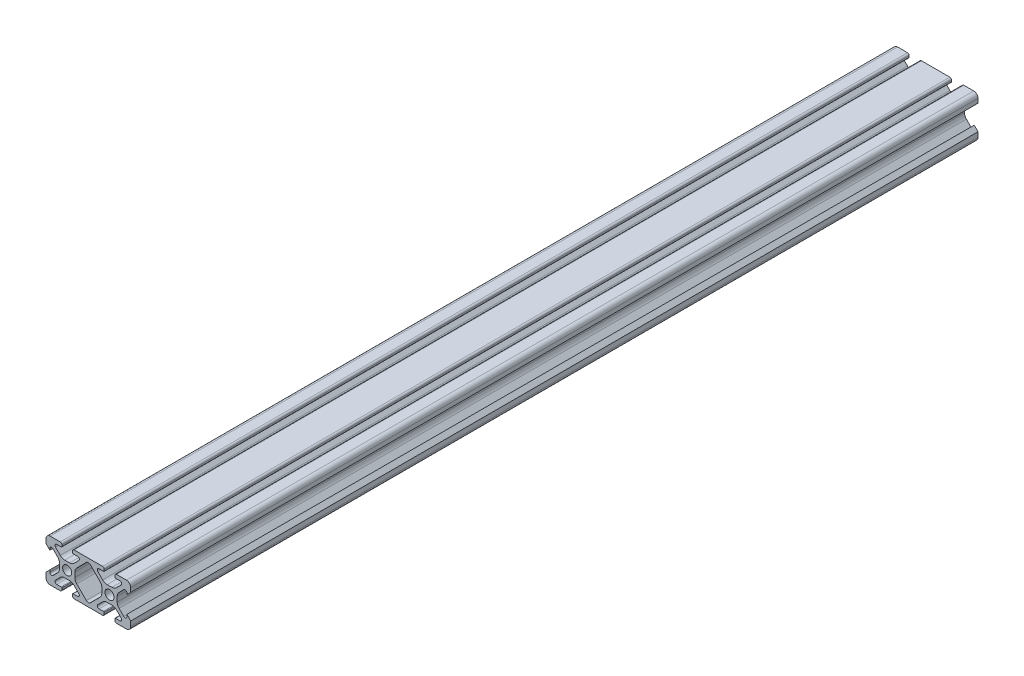
from build123d import *

# Parameters (mm, degrees)
SKETCH1_R           = 2.1463
BOSS_EXTRUDE1_DEPTH = 400
CUT_EXTRUDE1_DEPTH  = 401


with BuildPart() as part:
    # Sketch1 → Boss-Extrude1 (new body)
    with BuildSketch(Plane.XY):
        with BuildLine():
            Line((-19.9898, 7.9883), (-19.9898, 3.2893))
            ThreePointArc((-19.9898, 3.2893), (-19.75917588, 2.73252412), (-19.2024, 2.5019))
            Line((-19.2024, 2.5019), (-18.4912, 2.5019))
            ThreePointArc((-18.4912, 2.5019), (-18.275673853, 2.591173853), (-18.1864, 2.8067))
            Line((-18.1864, 2.8067), (-18.1864, 4.9149))
            ThreePointArc((-18.1864, 4.9149), (-17.668965253, 5.689295824), (-16.755503096, 5.507596904))
            Line((-16.755503096, 5.507596904), (-14.500665747, 3.252759555))
            ThreePointArc((-14.500665747, 3.252759555), (-13.850954457, 2.280397894), (-13.622806192, 1.133419111))
            Line((-13.622806192, 1.133419111), (-13.622806192, -1.133419111))
            ThreePointArc((-13.622806192, -1.133419111), (-13.850954457, -2.280397894), (-14.500665747, -3.252759555))
            Line((-14.500665747, -3.252759555), (-16.755503096, -5.507596904))
            ThreePointArc((-16.755503096, -5.507596904), (-17.668965253, -5.689295824), (-18.1864, -4.9149))
            Line((-18.1864, -4.9149), (-18.1864, -2.8067))
            ThreePointArc((-18.1864, -2.8067), (-18.275673853, -2.591173853), (-18.4912, -2.5019))
            Line((-18.4912, -2.5019), (-19.2024, -2.5019))
            ThreePointArc((-19.2024, -2.5019), (-19.75917588, -2.73252412), (-19.9898, -3.2893))
            Line((-19.9898, -3.2893), (-19.9898, -7.9883))
            ThreePointArc((-19.9898, -7.9883), (-19.402080467, -9.407180467), (-17.9832, -9.9949))
            Line((-17.9832, -9.9949), (-13.2842, -9.9949))
            ThreePointArc((-13.2842, -9.9949), (-12.72742412, -9.76427588), (-12.4968, -9.2075))
            Line((-12.4968, -9.2075), (-12.4968, -8.4963))
            ThreePointArc((-12.4968, -8.4963), (-12.586073853, -8.280773853), (-12.8016, -8.1915))
            Line((-12.8016, -8.1915), (-14.9098, -8.1915))
            ThreePointArc((-14.9098, -8.1915), (-15.684195824, -7.674065253), (-15.502496904, -6.760603096))
            Line((-15.502496904, -6.760603096), (-13.247659555, -4.505765747))
            ThreePointArc((-13.247659555, -4.505765747), (-12.275297894, -3.856054457), (-11.128319111, -3.627906192))
            Line((-11.128319111, -3.627906192), (-8.861480889, -3.627906192))
            ThreePointArc((-8.861480889, -3.627906192), (-7.714502106, -3.856054457), (-6.742140445, -4.505765747))
            Line((-6.742140445, -4.505765747), (-4.487303096, -6.760603096))
            ThreePointArc((-4.487303096, -6.760603096), (-4.305604176, -7.674065253), (-5.08, -8.1915))
            Line((-5.08, -8.1915), (-7.1882, -8.1915))
            ThreePointArc((-7.1882, -8.1915), (-7.403726147, -8.280773853), (-7.493, -8.4963))
            Line((-7.493, -8.4963), (-7.493, -9.2075))
            ThreePointArc((-7.493, -9.2075), (-7.26237588, -9.76427588), (-6.7056, -9.9949))
            Line((-6.7056, -9.9949), (0, -9.9949))
            Line((0, -9.9949), (6.7056, -9.9949))
            ThreePointArc((6.7056, -9.9949), (7.26237588, -9.76427588), (7.493, -9.2075))
            Line((7.493, -9.2075), (7.493, -8.4963))
            ThreePointArc((7.493, -8.4963), (7.403726147, -8.280773853), (7.1882, -8.1915))
            Line((7.1882, -8.1915), (5.08, -8.1915))
            ThreePointArc((5.08, -8.1915), (4.305604176, -7.674065253), (4.487303096, -6.760603096))
            Line((4.487303096, -6.760603096), (6.742140445, -4.505765747))
            ThreePointArc((6.742140445, -4.505765747), (7.714502106, -3.856054457), (8.861480889, -3.627906192))
            Line((8.861480889, -3.627906192), (11.128319111, -3.627906192))
            ThreePointArc((11.128319111, -3.627906192), (12.275297894, -3.856054457), (13.247659555, -4.505765747))
            Line((13.247659555, -4.505765747), (15.502496904, -6.760603096))
            ThreePointArc((15.502496904, -6.760603096), (15.684195824, -7.674065253), (14.9098, -8.1915))
            Line((14.9098, -8.1915), (12.8016, -8.1915))
            ThreePointArc((12.8016, -8.1915), (12.586073853, -8.280773853), (12.4968, -8.4963))
            Line((12.4968, -8.4963), (12.4968, -9.2075))
            ThreePointArc((12.4968, -9.2075), (12.72742412, -9.76427588), (13.2842, -9.9949))
            Line((13.2842, -9.9949), (17.9832, -9.9949))
            ThreePointArc((17.9832, -9.9949), (19.402080467, -9.407180467), (19.9898, -7.9883))
            Line((19.9898, -7.9883), (19.9898, -3.2893))
            ThreePointArc((19.9898, -3.2893), (19.75917588, -2.73252412), (19.2024, -2.5019))
            Line((19.2024, -2.5019), (18.4912, -2.5019))
            ThreePointArc((18.4912, -2.5019), (18.275673853, -2.591173853), (18.1864, -2.8067))
            Line((18.1864, -2.8067), (18.1864, -4.9149))
            ThreePointArc((18.1864, -4.9149), (17.668965253, -5.689295824), (16.755503096, -5.507596904))
            Line((16.755503096, -5.507596904), (14.500665747, -3.252759555))
            ThreePointArc((14.500665747, -3.252759555), (13.850954457, -2.280397894), (13.622806192, -1.133419111))
            Line((13.622806192, -1.133419111), (13.622806192, 1.133419111))
            ThreePointArc((13.622806192, 1.133419111), (13.850954457, 2.280397894), (14.500665747, 3.252759555))
            Line((14.500665747, 3.252759555), (16.755503096, 5.507596904))
            ThreePointArc((16.755503096, 5.507596904), (17.668965253, 5.689295824), (18.1864, 4.9149))
            Line((18.1864, 4.9149), (18.1864, 2.8067))
            ThreePointArc((18.1864, 2.8067), (18.275673853, 2.591173853), (18.4912, 2.5019))
            Line((18.4912, 2.5019), (19.2024, 2.5019))
            ThreePointArc((19.2024, 2.5019), (19.75917588, 2.73252412), (19.9898, 3.2893))
            Line((19.9898, 3.2893), (19.9898, 7.9883))
            ThreePointArc((19.9898, 7.9883), (19.402080467, 9.407180467), (17.9832, 9.9949))
            Line((17.9832, 9.9949), (13.2842, 9.9949))
            ThreePointArc((13.2842, 9.9949), (12.72742412, 9.76427588), (12.4968, 9.2075))
            Line((12.4968, 9.2075), (12.4968, 8.4963))
            ThreePointArc((12.4968, 8.4963), (12.586073853, 8.280773853), (12.8016, 8.1915))
            Line((12.8016, 8.1915), (14.9098, 8.1915))
            ThreePointArc((14.9098, 8.1915), (15.684195824, 7.674065253), (15.502496904, 6.760603096))
            Line((15.502496904, 6.760603096), (13.247659555, 4.505765747))
            ThreePointArc((13.247659555, 4.505765747), (12.275297894, 3.856054457), (11.128319111, 3.627906192))
            Line((11.128319111, 3.627906192), (8.861480889, 3.627906192))
            ThreePointArc((8.861480889, 3.627906192), (7.714502106, 3.856054457), (6.742140445, 4.505765747))
            Line((6.742140445, 4.505765747), (4.487303096, 6.760603096))
            ThreePointArc((4.487303096, 6.760603096), (4.305604176, 7.674065253), (5.08, 8.1915))
            Line((5.08, 8.1915), (7.1882, 8.1915))
            ThreePointArc((7.1882, 8.1915), (7.403726147, 8.280773853), (7.493, 8.4963))
            Line((7.493, 8.4963), (7.493, 9.2075))
            ThreePointArc((7.493, 9.2075), (7.26237588, 9.76427588), (6.7056, 9.9949))
            Line((6.7056, 9.9949), (0, 9.9949))
            Line((0, 9.9949), (-6.7056, 9.9949))
            ThreePointArc((-6.7056, 9.9949), (-7.26237588, 9.76427588), (-7.493, 9.2075))
            Line((-7.493, 9.2075), (-7.493, 8.4963))
            ThreePointArc((-7.493, 8.4963), (-7.403726147, 8.280773853), (-7.1882, 8.1915))
            Line((-7.1882, 8.1915), (-5.08, 8.1915))
            ThreePointArc((-5.08, 8.1915), (-4.305604176, 7.674065253), (-4.487303096, 6.760603096))
            Line((-4.487303096, 6.760603096), (-6.742140445, 4.505765747))
            ThreePointArc((-6.742140445, 4.505765747), (-7.714502106, 3.856054457), (-8.861480889, 3.627906192))
            Line((-8.861480889, 3.627906192), (-11.128319111, 3.627906192))
            ThreePointArc((-11.128319111, 3.627906192), (-12.275297894, 3.856054457), (-13.247659555, 4.505765747))
            Line((-13.247659555, 4.505765747), (-15.502496904, 6.760603096))
            ThreePointArc((-15.502496904, 6.760603096), (-15.684195824, 7.674065253), (-14.9098, 8.1915))
            Line((-14.9098, 8.1915), (-12.8016, 8.1915))
            ThreePointArc((-12.8016, 8.1915), (-12.586073853, 8.280773853), (-12.4968, 8.4963))
            Line((-12.4968, 8.4963), (-12.4968, 9.2075))
            ThreePointArc((-12.4968, 9.2075), (-12.72742412, 9.76427588), (-13.2842, 9.9949))
            Line((-13.2842, 9.9949), (-17.9832, 9.9949))
            ThreePointArc((-17.9832, 9.9949), (-19.402080467, 9.407180467), (-19.9898, 7.9883))
        make_face()
        with Locations((-9.9949, 0)):
            Circle(SKETCH1_R, mode=Mode.SUBTRACT)
        with Locations((9.9949, 0)):
            Circle(SKETCH1_R, mode=Mode.SUBTRACT)
        with BuildLine():
            Line((-6.366993808, 1.133419111), (-6.366993808, -1.133419111))
            ThreePointArc((-6.366993808, -1.133419111), (-6.138845543, -2.280397894), (-5.489134253, -3.252759555))
            Line((-5.489134253, -3.252759555), (-0.939581002, -7.802312806))
            ThreePointArc((-0.939581002, -7.802312806), (0, -8.1915), (0.939581002, -7.802312806))
            Line((0.939581002, -7.802312806), (5.489134253, -3.252759555))
            ThreePointArc((5.489134253, -3.252759555), (6.138845543, -2.280397894), (6.366993808, -1.133419111))
            Line((6.366993808, -1.133419111), (6.366993808, 1.133419111))
            ThreePointArc((6.366993808, 1.133419111), (6.138845543, 2.280397894), (5.489134253, 3.252759555))
            Line((5.489134253, 3.252759555), (0.939581002, 7.802312806))
            ThreePointArc((0.939581002, 7.802312806), (0, 8.1915), (-0.939581002, 7.802312806))
            Line((-0.939581002, 7.802312806), (-5.489134253, 3.252759555))
            ThreePointArc((-5.489134253, 3.252759555), (-6.138845543, 2.280397894), (-6.366993808, 1.133419111))
        make_face(mode=Mode.SUBTRACT)
    extrude(amount=BOSS_EXTRUDE1_DEPTH)

    # Sketch2 → Cut-Extrude1 (cut, through all)
    with BuildSketch(Plane.XY.offset(400)):
        Polygon((-20.360851008, 6.344750297), (-17.157785984, 3.141685274), (-17.157785984, -2.858314726), (-20.360851008, -6.06137975), align=None)
        Polygon((17.157785984, -2.858314726), (20.360851008, -6.06137975), (20.360851008, 6.344750297), (17.157785984, 3.141685274), align=None)
    extrude(amount=-CUT_EXTRUDE1_DEPTH, mode=Mode.SUBTRACT)


solid = part.part
